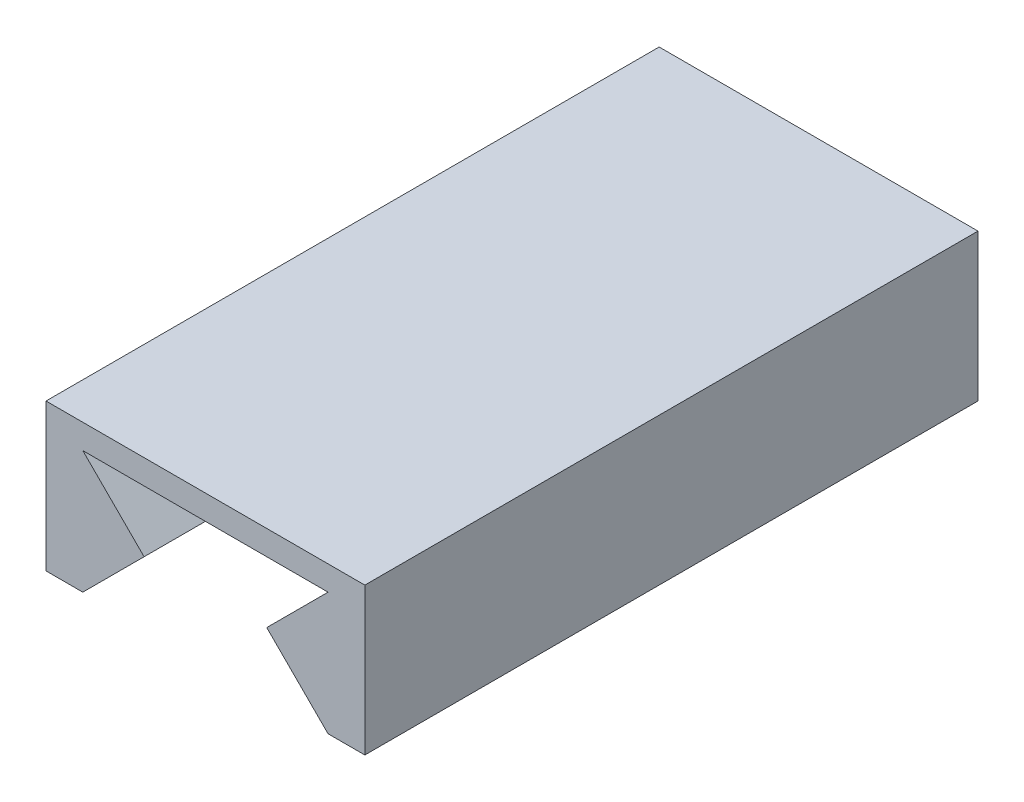
from build123d import *

# Parameters (mm, degrees)
Y_KSEKLIK_EKSTR_ZYON1_DEPTH = 50


with BuildPart() as part:
    # Çizim1 → Yükseklik-Ekstrüzyon1 (new body)
    with BuildSketch(Plane.XY):
        Polygon((0, 0), (-5, -5), (-8, -5), (-8, 7), (18, 7), (18, -5), (15, -5), (10, 0), (15, 5), (-5, 5), align=None)
    extrude(amount=Y_KSEKLIK_EKSTR_ZYON1_DEPTH)


solid = part.part
